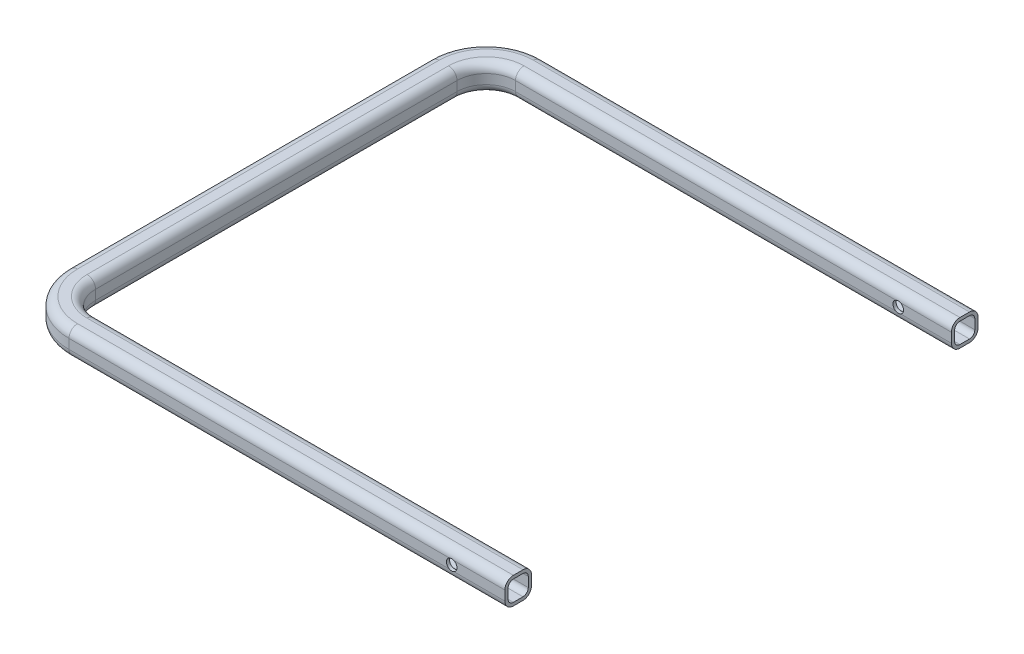
from build123d import *

# Parameters (mm, degrees)
SKETCH3_R               = 5
CUT_EXTRUDE1_DEPTH      = 13.5000001
CUT_EXTRUDE1_DEPTH_BACK = 433.5000001


with BuildPart() as part:
    # Sweep-Thin1: sweep along a path in Sketch1
    with BuildLine(Plane(origin=(0, 0, 0), x_dir=(1, 0, 0), z_dir=(0, 1, 0))) as sweep_thin1_path:
        Line((0, 0), (-410, 0))
        ThreePointArc((-410, 0), (-438.284271247, 11.715728753), (-450, 40))
        Line((-450, 40), (-450, 380))
        ThreePointArc((-450, 380), (-438.284271247, 408.284271247), (-410, 420))
        Line((-410, 420), (0, 420))
    # Sketch2 → Sweep-Thin1 (sweep)
    with BuildSketch(Plane(origin=(0, 0, 0), x_dir=(0, 0, -1), z_dir=(1, 0, 0))):
        with BuildLine():
            Line((4.5, 12.5), (-4.5, 12.5))
            ThreePointArc((-4.5, 12.5), (-10.156854249, 10.156854249), (-12.5, 4.5))
            Line((-12.5, 4.5), (-12.5, -4.5))
            ThreePointArc((-12.5, -4.5), (-10.156854249, -10.156854249), (-4.5, -12.5))
            Line((-4.5, -12.5), (4.5, -12.5))
            ThreePointArc((4.5, -12.5), (10.156854249, -10.156854249), (12.5, -4.5))
            Line((12.5, -4.5), (12.5, 4.5))
            ThreePointArc((12.5, 4.5), (10.156854249, 10.156854249), (4.5, 12.5))
        make_face()
        with BuildLine():
            Line((4.5, 9.5), (-4.5, 9.5))
            ThreePointArc((-4.5, 9.5), (-8.035533906, 8.035533906), (-9.5, 4.5))
            Line((-9.5, 4.5), (-9.5, -4.5))
            ThreePointArc((-9.5, -4.5), (-8.035533906, -8.035533906), (-4.5, -9.5))
            Line((-4.5, -9.5), (4.5, -9.5))
            ThreePointArc((4.5, -9.5), (8.035533906, -8.035533906), (9.5, -4.5))
            Line((9.5, -4.5), (9.5, 4.5))
            ThreePointArc((9.5, 4.5), (8.035533906, 8.035533906), (4.5, 9.5))
        make_face(mode=Mode.SUBTRACT)
    sweep(path=sweep_thin1_path.line)

    # Sketch3 → Cut-Extrude1 (cut, two sides)
    with BuildSketch(Plane.XY) as cut_extrude1_sk:
        with Locations((-50, 0)):
            Circle(SKETCH3_R)
    extrude(amount=CUT_EXTRUDE1_DEPTH, mode=Mode.SUBTRACT)
    extrude(cut_extrude1_sk.sketch, amount=-CUT_EXTRUDE1_DEPTH_BACK, mode=Mode.SUBTRACT)


solid = part.part
